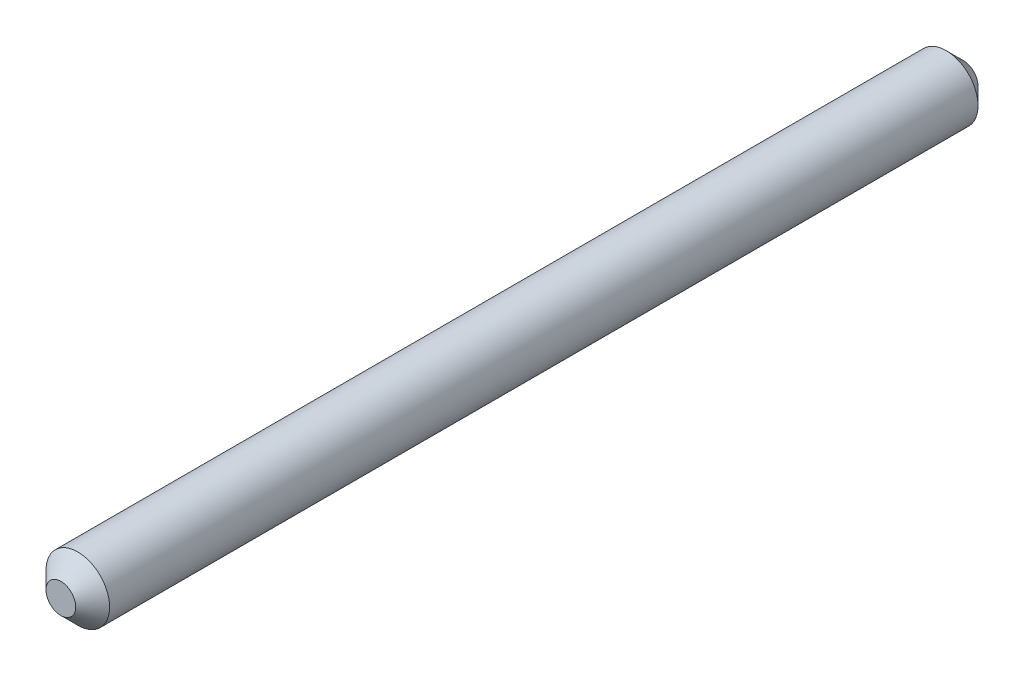
from build123d import *

# Parameters (mm, degrees)
SKETCH1_R           = 2.38125
BOSS_EXTRUDE1_DEPTH = 67.564
CHAMFER1_SIZE       = 1.27


with BuildPart() as part:
    # Sketch1 → Boss-Extrude1 (new body)
    with BuildSketch(Plane.XY):
        Circle(SKETCH1_R)
    extrude(amount=-BOSS_EXTRUDE1_DEPTH)

    # Chamfer1
    chamfer1_edges = [part.edges().sort_by_distance(p)[0] for p in [
        (-2.38125, 0, 0),
        (-2.38125, 0, -67.564),
    ]]
    chamfer(chamfer1_edges, length=CHAMFER1_SIZE)


solid = part.part
